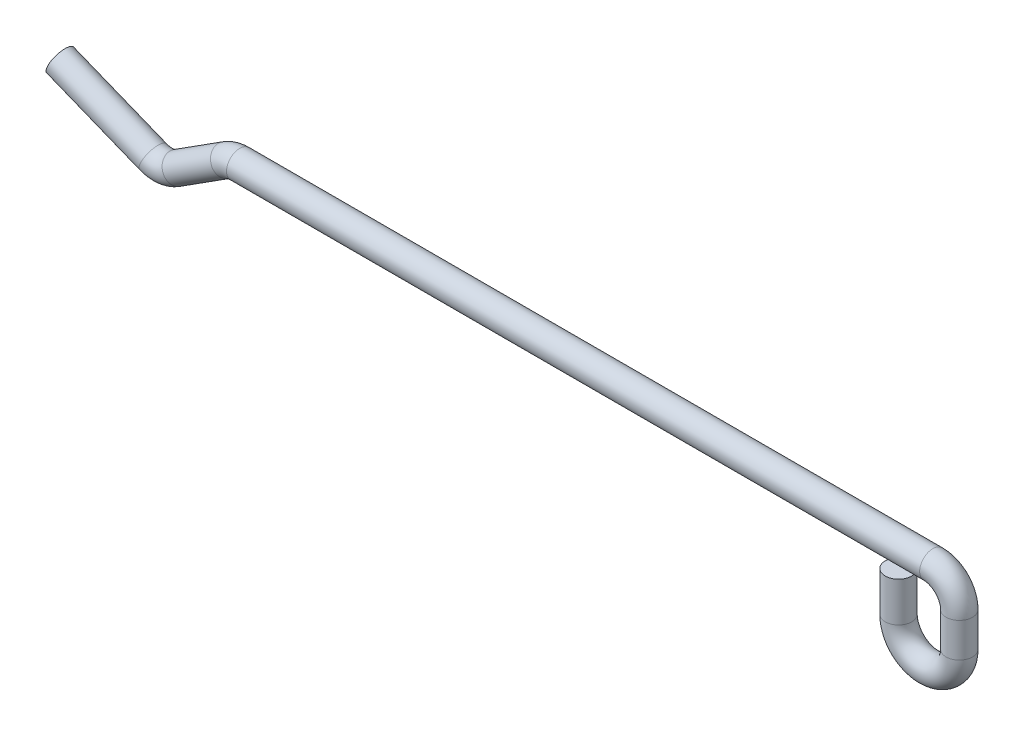
from build123d import *

# Parameters (mm, degrees)
ESQUISSE2_R = 1


with BuildPart() as part:
    # Balayage1: sweep along a path in Esquisse1
    with BuildLine(Plane.XY) as balayage1_path:
        Line((-63.4, 1.6), (-56.371023239, -1.217761314))
        ThreePointArc((-56.371023239, -1.217761314), (-55.440643854, -1.352684575), (-54.551404356, -1.047621953))
        Line((-54.551404356, -1.047621953), (-50.891949681, 1.286251527))
        ThreePointArc((-50.891949681, 1.286251527), (-50.376649394, 1.519961335), (-49.816516844, 1.6))
        Line((-49.816516844, 1.6), (2.6, 1.6))
        ThreePointArc((2.6, 1.6), (4.014213562, 1.014213562), (4.6, -0.4))
        Line((4.6, -0.4), (4.6, -3))
        ThreePointArc((4.6, -3), (2.3, -5.3), (0, -3))
        Line((0, -3), (0, 0))
    # Esquisse2 → Balayage1 (sweep)
    with BuildSketch(Plane(origin=(0, 0, 0), x_dir=(1, 0, 0), z_dir=(0, 1, 0))):
        Circle(ESQUISSE2_R)
    sweep(path=balayage1_path.line)


solid = part.part
